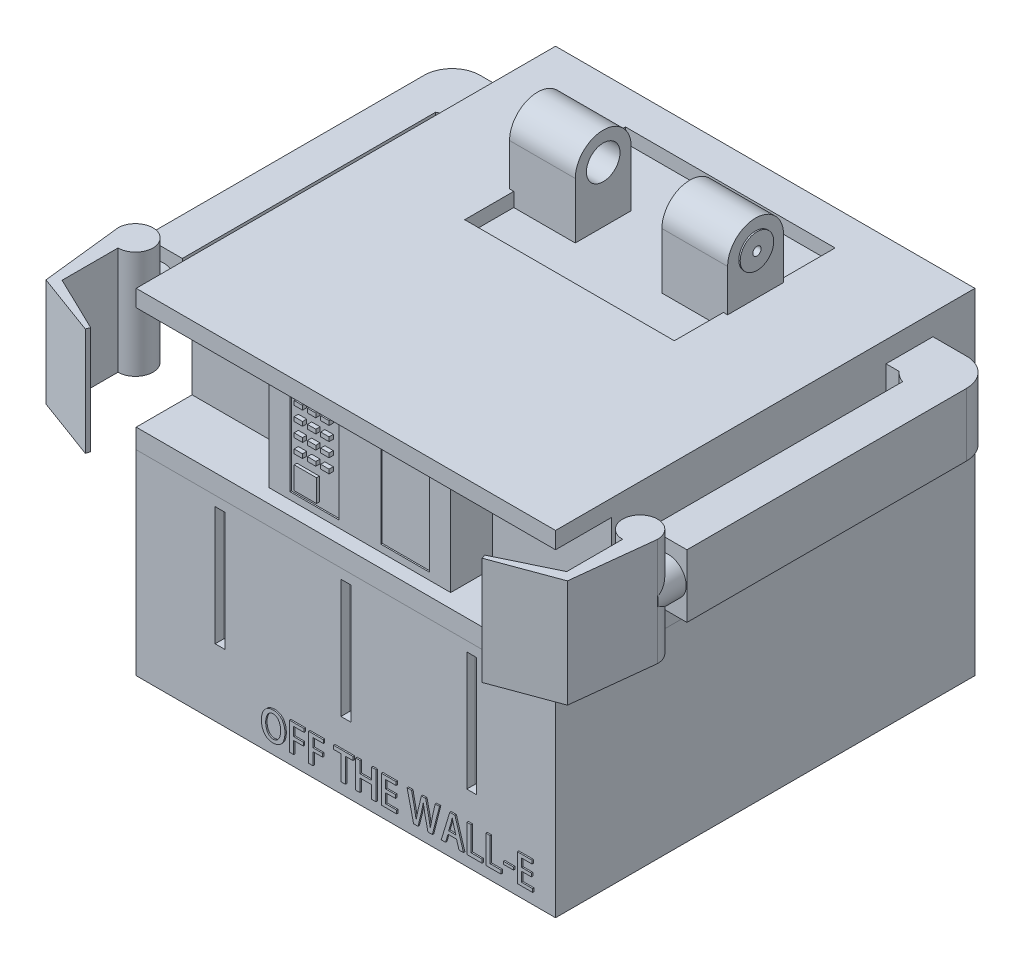
from build123d import *

# Parameters (mm, degrees)
BASE_W                                = 15
BASE_H                                = 15
BOTTOM_BASE_DEPTH                     = 7
BASE2_W                               = 15
BASE2_H                               = 15
TOP_BASE_DEPTH                        = 5
SKETCH3_W                             = 15
SKETCH3_H                             = 3.7
TOP_CUT_DEPTH                         = 2
SKETCH4_W                             = 6.5
SKETCH4_H                             = 3.7
BIG_BUTTON_PLATE_DEPTH                = 1.5
SKETCH6_W                             = 0.3
SKETCH6_H                             = 0.15
F_3X4_BUTTONS_DEPTH                   = 0.1
SKETCH9_W                             = 0.8
SKETCH9_H                             = 0.8
BIG_SQUARE_BUTTON_DEPTH               = 0.1
SKETCH6_6_W                           = 1.75
SKETCH6_6_H                           = 3.2
SKETCH6_6_W_2                         = 0.3
SKETCH6_6_H_2                         = 0.15
PHONE_DEPTH                           = 0.05
SKETCH14_W                            = 0.35
SKETCH14_H                            = 4.25
F_3_BOTTOM_SLOTS_DEPTH                = 0.35
FILLET1_R                             = 0.05
SKETCH15_W                            = 7.5
SKETCH15_H                            = 5.75
TOP_EXTRUDE_CUT_DEPTH                 = 0.5
RIGHT_HEAD_HOLDER_1_DEPTH             = 2.2
RIGHT_HEAD_HOLDER_1_DEPTH_BACK        = 0.15
SKETCH19_R                            = 0.6
RIGHT_HEAD_HOLDER_2_DEPTH             = 0.35
RIGHT_HEAD_HOLDER_2_DEPTH_BACK        = 0.2
SKETCH19_3_R                          = 0.6
SKETCH19_3_R_2                        = 0.15
LEFT_HEAD_HOLDER_1_DEPTH              = 2.2
LEFT_HEAD_HOLDER_1_DEPTH_BACK         = 0.15
SKETCH18_R                            = 0.6
LEFT_HEAD_HOLDER_2_DEPTH              = 0.35
LEFT_HEAD_HOLDER_2_DEPTH_BACK         = 0.2
SKETCH18_3_R                          = 0.6
SKETCH18_3_R_2                        = 0.15
ARMS_DEPTH                            = 2.25
CLAWS_DEPTH                           = 0.8
CLAWS_DEPTH_BACK                      = 3.05
CLAWS_2_DEPTH                         = 0.8
CLAWS_2_DEPTH_BACK                    = 3.05
SKETCH26_R                            = 0.65
CIRCLE_TO_ATTACH_ARMS_AND_CLAWS_DEPTH = 1
SKETCH28_W                            = 0.359189424
SKETCH28_H                            = 0.095238297
BOSS_EXTRUDE26_DEPTH                  = 0.05
SKETCH33_W                            = 1.285714286
SKETCH33_H                            = 1.285714286
CUT_EXTRUDE1_DEPTH                    = 2.892857143
SCALE1_SCALE                          = 1.4


with BuildPart() as part:
    # Base → Bottom base (new body)
    with BuildSketch(Plane(origin=(0, 0, 0), x_dir=(1, 0, 0), z_dir=(0, 1, 0))):
        Rectangle(BASE_W, BASE_H)
    extrude(amount=BOTTOM_BASE_DEPTH)

    # Sketch14 → 3 bottom slots (cut)
    with BuildSketch(Plane.XY.offset(7.5)):
        with Locations((0, 4.525)):
            Rectangle(SKETCH14_W, SKETCH14_H)
        with Locations((4.5, 4.525)):
            Rectangle(SKETCH14_W, SKETCH14_H)
        with Locations((-4.5, 4.525)):
            Rectangle(SKETCH14_W, SKETCH14_H)
    extrude(amount=-F_3_BOTTOM_SLOTS_DEPTH, mode=Mode.SUBTRACT)

    # Fillet1
    fillet1_edges = [part.edges().sort_by_distance(p)[0] for p in [
        (-0.175, 4.525, 7.15),
        (-4.675, 4.525, 7.15),
        (4.675, 4.525, 7.15),
        (4.5, 6.65, 7.15),
        (0.175, 4.525, 7.15),
        (0, 6.65, 7.15),
        (4.325, 4.525, 7.15),
        (4.5, 2.4, 7.15),
        (0, 2.4, 7.15),
        (-4.5, 2.4, 7.15),
        (-4.5, 6.65, 7.15),
        (-4.325, 4.525, 7.15),
    ]]
    fillet(fillet1_edges, radius=FILLET1_R)

    # Sketch28 → Boss-Extrude26 (add)
    # profile 1 of 12: a face of its own
    with BuildSketch(Plane.XY.offset(7.5)):
        with BuildLine():
            add(Edge.make_bspline(
                [(-2.542773415, 1.438775136), (-2.55882584, 1.438110923), (-2.59017136, 1.436813916), (-2.635834672, 1.429654226), (-2.678976734, 1.41865114), (-2.719463386, 1.403035452), (-2.757423202, 1.38326681), (-2.792716073, 1.359116703), (-2.825399223, 1.330752787), (-2.855279169, 1.298345473), (-2.882055278, 1.262197262), (-2.905669966, 1.222690536), (-2.925377124, 1.17977718), (-2.941932195, 1.133846801), (-2.954655386, 1.08466898), (-2.964079137, 1.032377645), (-2.969951963, 0.976854424), (-2.97105014, 0.938758011), (-2.971613422, 0.919217401)],
                knots=[0, 0, 0, 0, 1.01693825, 1.985772131, 2.921518734, 3.832117633, 4.727948323, 5.626511184, 6.534414133, 7.463288783, 8.412839634, 9.378967074, 10.373196777, 11.399194858, 12.46754142, 13.586614818, 14.762113956, 16, 16, 16, 16], degree=3))
            add(Edge.make_bspline(
                [(-2.971613422, 0.919217401), (-2.971208289, 0.900429172), (-2.970416523, 0.863710668), (-2.964426968, 0.810220053), (-2.956119813, 0.759588063), (-2.943575482, 0.712087769), (-2.928381776, 0.667333139), (-2.909052276, 0.625858504), (-2.886964026, 0.587076746), (-2.8612577, 0.55170149), (-2.832800775, 0.519545639), (-2.801228268, 0.491619405), (-2.766992422, 0.46781399), (-2.730017847, 0.448191723), (-2.690284694, 0.432873966), (-2.647883002, 0.421784598), (-2.602861971, 0.414647273), (-2.571917352, 0.413420404), (-2.556080466, 0.412792516)],
                knots=[0, 0, 0, 0, 1.222557966, 2.38928844, 3.500048728, 4.559063003, 5.583344684, 6.572073494, 7.532658458, 8.483942143, 9.413076429, 10.322121769, 11.220566177, 12.121066096, 13.040014193, 13.985715855, 14.969126498, 16, 16, 16, 16], degree=3))
            add(Edge.make_bspline(
                [(-2.556080466, 0.412792516), (-2.54075349, 0.413188806), (-2.510669922, 0.41396664), (-2.466682885, 0.420165519), (-2.424842983, 0.430077083), (-2.38526705, 0.444305975), (-2.348009795, 0.462822842), (-2.312864376, 0.485189664), (-2.279982063, 0.511738917), (-2.249253561, 0.542102642), (-2.221648907, 0.576876857), (-2.197202941, 0.615672953), (-2.176945288, 0.65894639), (-2.159942527, 0.706133976), (-2.146555767, 0.757497133), (-2.136920145, 0.812927523), (-2.130587189, 0.872528944), (-2.12942961, 0.913657954), (-2.12883171, 0.934901455)],
                knots=[0, 0, 0, 0, 0.964759122, 1.89361537, 2.791129421, 3.668077106, 4.535429534, 5.405715028, 6.285894481, 7.191747456, 8.120239528, 9.075412678, 10.072429751, 11.12252868, 12.229792465, 13.410030886, 14.662257747, 16, 16, 16, 16], degree=3))
            add(Edge.make_bspline(
                [(-2.12883171, 0.934901455), (-2.129145052, 0.95299104), (-2.12975776, 0.988363246), (-2.134927432, 1.040094869), (-2.143460291, 1.089133126), (-2.154882139, 1.135699503), (-2.169797366, 1.179671389), (-2.188169567, 1.221026594), (-2.209857994, 1.259758826), (-2.234383469, 1.295895008), (-2.262423291, 1.328524563), (-2.293489849, 1.357214635), (-2.327622631, 1.381751634), (-2.365000455, 1.401492806), (-2.405152647, 1.417631026), (-2.44846881, 1.428920554), (-2.494667177, 1.436482788), (-2.526508763, 1.437935279), (-2.542773415, 1.438775136)],
                knots=[0, 0, 0, 0, 1.181997023, 2.311265979, 3.393394717, 4.432710499, 5.441572568, 6.423779709, 7.385757606, 8.339154063, 9.273212536, 10.190881701, 11.096730823, 12.012033381, 12.946898792, 13.918455472, 14.931549697, 16, 16, 16, 16], degree=3))
        make_face()
        with BuildLine():
            add(Edge.make_bspline(
                [(-2.548066636, 1.31991609), (-2.537165417, 1.318983992), (-2.515855441, 1.317161903), (-2.484981242, 1.31054518), (-2.456310213, 1.300351113), (-2.429814447, 1.286594966), (-2.405742403, 1.269172675), (-2.383543332, 1.248629521), (-2.363840451, 1.224383101), (-2.346717009, 1.196948695), (-2.331589955, 1.167451879), (-2.318430785, 1.13658356), (-2.306908464, 1.104796692), (-2.29799648, 1.071757069), (-2.290669647, 1.037788882), (-2.285934581, 1.002655396), (-2.282735348, 0.966518333), (-2.282427136, 0.942026369), (-2.282270891, 0.929610449)],
                knots=[0, 0, 0, 0, 0.999589655, 1.954022852, 2.877517249, 3.773878129, 4.673599429, 5.586311784, 6.531597741, 7.520501744, 8.537853166, 9.559417173, 10.586727125, 11.626167667, 12.685579831, 13.761408337, 14.865171654, 16, 16, 16, 16], degree=3))
            add(Edge.make_bspline(
                [(-2.282270891, 0.929610449), (-2.282515675, 0.916063238), (-2.282995612, 0.889501882), (-2.28596674, 0.850426095), (-2.29128527, 0.813015414), (-2.298562117, 0.777117744), (-2.308300047, 0.742958305), (-2.31968806, 0.710261892), (-2.333651813, 0.679388185), (-2.349250923, 0.650198013), (-2.36712996, 0.623475447), (-2.387135503, 0.599901927), (-2.409359173, 0.579747293), (-2.433601588, 0.563029952), (-2.460016367, 0.549834402), (-2.488459567, 0.540284041), (-2.518878394, 0.533600178), (-2.539982794, 0.532311215), (-2.550789459, 0.531651192)],
                knots=[0, 0, 0, 0, 1.215141369, 2.382468418, 3.512223075, 4.602497428, 5.664896563, 6.695933009, 7.704955915, 8.700973005, 9.661508233, 10.583141316, 11.467103885, 12.344670232, 13.216342825, 14.106081872, 15.030205112, 16, 16, 16, 16], degree=3))
            add(Edge.make_bspline(
                [(-2.550789459, 0.531651192), (-2.561404923, 0.532397393), (-2.582186513, 0.53385821), (-2.612268391, 0.540448671), (-2.640452786, 0.550215414), (-2.666522509, 0.563599601), (-2.690700767, 0.580196186), (-2.712602066, 0.600478458), (-2.732893267, 0.623866029), (-2.750494325, 0.650723065), (-2.766275355, 0.679738522), (-2.7800325, 0.710402286), (-2.791879883, 0.742433556), (-2.80114964, 0.77598823), (-2.808854497, 0.810774186), (-2.814005122, 0.846973579), (-2.817330483, 0.884511626), (-2.817764383, 0.910013807), (-2.817985276, 0.922996691)],
                knots=[0, 0, 0, 0, 0.968573833, 1.896149455, 2.796477749, 3.679461465, 4.558257033, 5.460120664, 6.392036362, 7.372592241, 8.379386201, 9.399199485, 10.432362265, 11.48798156, 12.568687675, 13.676620176, 14.817192429, 16, 16, 16, 16], degree=3))
            add(Edge.make_bspline(
                [(-2.817985276, 0.922996691), (-2.817906472, 0.93566455), (-2.817750586, 0.960723784), (-2.814512109, 0.997678677), (-2.809767876, 1.033623912), (-2.802495327, 1.068302048), (-2.793463414, 1.101907221), (-2.782305831, 1.13439706), (-2.768830302, 1.165645515), (-2.753760089, 1.19566964), (-2.736462485, 1.223413999), (-2.716446665, 1.247918927), (-2.69405673, 1.268812858), (-2.669357094, 1.286293929), (-2.642284347, 1.300124753), (-2.612952929, 1.310551542), (-2.58132124, 1.317484158), (-2.559390721, 1.319029602), (-2.548066636, 1.31991609)],
                knots=[0, 0, 0, 0, 1.136547726, 2.248289582, 3.326834991, 4.389002452, 5.425786828, 6.448433384, 7.469124786, 8.477926495, 9.461316408, 10.397265518, 11.309260955, 12.201738065, 13.104381261, 14.028854752, 14.989125284, 16, 16, 16, 16], degree=3))
        make_face(mode=Mode.SUBTRACT)
    # profile 2 of 12: a face of its own
    with BuildSketch(Plane.XY.offset(7.5)):
        Polygon((-1.814205801, 0.421490419), (-1.814205801, 0.860354587), (-1.471996241, 0.860354587), (-1.471996241, 0.979213633), (-1.814205801, 0.979213633), (-1.814205801, 1.295728633), (-1.445873374, 1.295728633), (-1.445873374, 1.414587678), (-1.967645167, 1.414587678), (-1.967645167, 0.421490419), align=None)
    # profile 3 of 12: a face of its own
    with BuildSketch(Plane.XY.offset(7.5)):
        Polygon((-1.12486327, 0.421490419), (-1.12486327, 0.860354587), (-0.782653711, 0.860354587), (-0.782653711, 0.979213633), (-1.12486327, 0.979213633), (-1.12486327, 1.295728633), (-0.756530843, 1.295728633), (-0.756530843, 1.414587678), (-1.278302637, 1.414587678), (-1.278302637, 0.421490419), align=None)
    # profile 4 of 12: a face of its own
    with BuildSketch(Plane.XY.offset(7.5)):
        Polygon((0.306506351, 1.425859116), (-0.386370222, 1.425859116), (-0.386370222, 1.296550924), (-0.11730469, 1.296550924), (-0.11730469, 0.426659447), (0.036134676, 0.426659447), (0.036134676, 1.296550924), (0.306506351, 1.296550924), align=None)
    # profile 5 of 12: a face of its own
    with BuildSketch(Plane.XY.offset(7.5)):
        Polygon((1.124570067, 1.428519382), (0.971130701, 1.428519382), (0.971130701, 1.015778081), (0.556165007, 1.015778081), (0.556165007, 1.428519382), (0.40272564, 1.428519382), (0.40272564, 0.429720894), (0.556165007, 0.429720894), (0.556165007, 0.884258782), (0.971130701, 0.884258782), (0.971130701, 0.429720894), (1.124570067, 0.429720894), align=None)
    # profile 6 of 12: a face of its own
    with BuildSketch(Plane.XY.offset(7.5)):
        Polygon((1.868437532, 0.543839587), (1.475288381, 0.543839587), (1.475288381, 0.884542045), (1.825334801, 0.884542045), (1.825334801, 1.00340109), (1.475288381, 1.00340109), (1.475288381, 1.295728633), (1.846233095, 1.295728633), (1.846233095, 1.414587678), (1.321849015, 1.414587678), (1.321849015, 0.424980542), (1.868437532, 0.424980542), align=None)
    # profile 7 of 12: a face of its own
    with BuildSketch(Plane.XY.offset(7.5)):
        with BuildLine():
            Line((3.245765887, 1.425831067), (3.139055562, 0.953960298))
            add(Edge.make_bspline(
                [(3.139055562, 0.953960298), (3.132663135, 0.924375836), (3.119998725, 0.865764336), (3.1020337, 0.778168135), (3.085930576, 0.690954756), (3.07705063, 0.63264649), (3.07260538, 0.603457706)],
                knots=[0, 0, 0, 0, 1.01788206, 2.01658543, 3.007114032, 4, 4, 4, 4], degree=3))
            Line((3.07260538, 0.603457706), (3.068782909, 0.603457706))
            add(Edge.make_bspline(
                [(3.068782909, 0.603457706), (3.064621305, 0.632259681), (3.056258443, 0.690138076), (3.041702599, 0.777037426), (3.025081799, 0.864413942), (3.012568145, 0.922642729), (3.006278837, 0.951908261)],
                knots=[0, 0, 0, 0, 0.986163973, 1.981724799, 2.985623747, 4, 4, 4, 4], degree=3))
            Line((3.006278837, 0.951908261), (2.902210694, 1.426964854))
            Line((2.902210694, 1.426964854), (2.751254624, 1.426964854))
            Line((2.751254624, 1.426964854), (2.638037571, 0.954592148))
            add(Edge.make_bspline(
                [(2.638037571, 0.954592148), (2.630872403, 0.923406884), (2.61681508, 0.862224604), (2.596699251, 0.772299255), (2.578665214, 0.686135246), (2.569505115, 0.629634853), (2.565046708, 0.602134954)],
                knots=[0, 0, 0, 0, 1.066520868, 2.092404214, 3.071534041, 4, 4, 4, 4], degree=3))
            Line((2.565046708, 0.602134954), (2.562559536, 0.602140121))
            add(Edge.make_bspline(
                [(2.562559536, 0.602140121), (2.560300099, 0.615428557), (2.55570602, 0.642447728), (2.54874011, 0.683653591), (2.541417455, 0.726190662), (2.530665073, 0.785077644), (2.516739752, 0.860534551), (2.504767173, 0.921245095), (2.498720165, 0.951908261)],
                knots=[0, 0, 0, 0, 0.682369738, 1.387451828, 2.115611866, 2.867419731, 4.417822979, 6, 6, 6, 6], degree=3))
            Line((2.498720165, 0.951908261), (2.399891357, 1.426964854))
            Line((2.399891357, 1.426964854), (2.239838602, 1.426964854))
            Line((2.239838602, 1.426964854), (2.472766701, 0.425831067))
            Line((2.472766701, 0.425831067), (2.631530844, 0.425831067))
            Line((2.631530844, 0.425831067), (2.749953278, 0.910045241))
            add(Edge.make_bspline(
                [(2.749953278, 0.910045241), (2.753617344, 0.924555813), (2.760831191, 0.953124366), (2.770726599, 0.995475919), (2.780283244, 1.03650652), (2.791843212, 1.089662653), (2.80499902, 1.155496718), (2.813336322, 1.208364765), (2.817503292, 1.234788132)],
                knots=[0, 0, 0, 0, 0.811805786, 1.598290927, 2.359154387, 3.097023541, 4.549096894, 6, 6, 6, 6], degree=3))
            Line((2.817503292, 1.234788132), (2.821527277, 1.234976727))
            add(Edge.make_bspline(
                [(2.821527277, 1.234976727), (2.82469568, 1.208365765), (2.831034187, 1.155129548), (2.844522693, 1.075106184), (2.860318642, 0.993345399), (2.872490004, 0.938213226), (2.878727794, 0.90995814)],
                knots=[0, 0, 0, 0, 0.973823886, 1.948170723, 2.948443182, 4, 4, 4, 4], degree=3))
            Line((2.878727794, 0.90995814), (2.986798147, 0.425831067))
            Line((2.986798147, 0.425831067), (3.144260944, 0.425831067))
            Line((3.144260944, 0.425831067), (3.399324648, 1.426964854))
            Line((3.399324648, 1.426964854), (3.245765887, 1.425831067))
        make_face()
    # profile 8 of 12: a face of its own
    with BuildSketch(Plane.XY.offset(7.5)):
        Polygon((3.9523852, 1.426512188), (3.766939047, 1.426512188), (3.461305192, 0.421347588), (3.616753782, 0.421347588), (3.702947065, 0.715229844), (4.008541429, 0.715229844), (4.098652588, 0.421347588), (4.257979564, 0.421347588), align=None)
        with BuildLine():
            Line((3.726454323, 0.83408889), (3.806117812, 1.098552471))
            add(Edge.make_bspline(
                [(3.806117812, 1.098552471), (3.810378493, 1.114590054), (3.819076241, 1.147329146), (3.83055211, 1.197153881), (3.841903727, 1.246876142), (3.849377993, 1.279761021), (3.853028805, 1.295823669)],
                knots=[0, 0, 0, 0, 0.981880665, 2.004409445, 3.025252049, 4, 4, 4, 4], degree=3))
            Line((3.853028805, 1.295823669), (3.855744247, 1.295897852))
            add(Edge.make_bspline(
                [(3.855744247, 1.295897852), (3.859406222, 1.279929837), (3.866906617, 1.247224421), (3.878892873, 1.19768297), (3.891585867, 1.147389791), (3.900662415, 1.113901091), (3.905183009, 1.097221969)],
                knots=[0, 0, 0, 0, 0.960134074, 1.966530216, 2.987225846, 4, 4, 4, 4], degree=3))
            Line((3.905183009, 1.097221969), (3.983728212, 0.83408889))
            Line((3.983728212, 0.83408889), (3.726454323, 0.83408889))
        make_face(mode=Mode.SUBTRACT)
    # profile 9 of 12: a face of its own
    with BuildSketch(Plane.XY.offset(7.5)):
        Polygon((4.92031401, 0.555082791), (4.53500172, 0.555082791), (4.53500172, 1.426280411), (4.381562353, 1.426280411), (4.381562353, 0.425831067), (4.92031401, 0.425831067), align=None)
    # profile 10 of 12: a face of its own
    with BuildSketch(Plane.XY.offset(7.5)):
        Polygon((5.597562813, 0.555082791), (5.212250522, 0.555082791), (5.212250522, 1.426280411), (5.058811156, 1.426280411), (5.058811156, 0.425831067), (5.597562813, 0.425831067), align=None)
    # profile 11 of 12: a face of its own
    with BuildSketch(Plane.XY.offset(7.5)):
        with Locations((5.867201512, 0.823034374)):
            Rectangle(SKETCH28_W, SKETCH28_H)
    # profile 12 of 12: a face of its own
    with BuildSketch(Plane.XY.offset(7.5)):
        Polygon((6.730116434, 0.543839587), (6.336967283, 0.543839587), (6.336967283, 0.884542045), (6.687013703, 0.884542045), (6.687013703, 1.00340109), (6.336967283, 1.00340109), (6.336967283, 1.295728633), (6.707911996, 1.295728633), (6.707911996, 1.414587678), (6.183527917, 1.414587678), (6.183527917, 0.424980542), (6.730116434, 0.424980542), align=None)
    extrude(amount=BOSS_EXTRUDE26_DEPTH)

    # Sketch33 → Cut-Extrude1 (cut)
    with BuildSketch(Plane.XZ):
        with Locations((-6.414285714, 0.1)):
            Rectangle(SKETCH33_W, SKETCH33_H)
        with Locations((6.414285714, 0.1)):
            Rectangle(SKETCH33_W, SKETCH33_H)
    extrude(amount=-CUT_EXTRUDE1_DEPTH, mode=Mode.SUBTRACT)


with BuildPart() as body_2:
    # Base2 → Top base (new body)
    with BuildSketch(Plane(origin=(0, 7, 0), x_dir=(1, 0, 0), z_dir=(0, 1, 0))):
        Rectangle(BASE2_W, BASE2_H)
    extrude(amount=TOP_BASE_DEPTH)

    # Sketch3 → Top cut (cut)
    with BuildSketch(Plane.XY.offset(7.5)):
        with Locations((0, 9.55)):
            Rectangle(SKETCH3_W, SKETCH3_H)
    extrude(amount=-TOP_CUT_DEPTH, mode=Mode.SUBTRACT)

    # Sketch4 → Big button plate (add)
    with BuildSketch(Plane.XY.offset(5.5)):
        with Locations((0, 9.55)):
            Rectangle(SKETCH4_W, SKETCH4_H)
    extrude(amount=BIG_BUTTON_PLATE_DEPTH)

    # Sketch6 → 3x4 buttons (add)
    with BuildSketch(Plane.XY.offset(7)):
        with Locations((-1.625, 10.874059361)):
            Rectangle(SKETCH6_W, SKETCH6_H)
        with Locations((-2.1, 10.874059361)):
            Rectangle(SKETCH6_W, SKETCH6_H)
        with Locations((-1.15, 10.874059361)):
            Rectangle(SKETCH6_W, SKETCH6_H)
        with Locations((-2.1, 10.374059361)):
            Rectangle(SKETCH6_W, SKETCH6_H)
        with Locations((-1.625, 10.374059361)):
            Rectangle(SKETCH6_W, SKETCH6_H)
        with Locations((-1.15, 10.374059361)):
            Rectangle(SKETCH6_W, SKETCH6_H)
        with Locations((-2.1, 9.874059361)):
            Rectangle(SKETCH6_W, SKETCH6_H)
        with Locations((-1.625, 9.874059361)):
            Rectangle(SKETCH6_W, SKETCH6_H)
        with Locations((-1.15, 9.874059361)):
            Rectangle(SKETCH6_W, SKETCH6_H)
        with Locations((-2.1, 9.374059361)):
            Rectangle(SKETCH6_W, SKETCH6_H)
        with Locations((-1.625, 9.374059361)):
            Rectangle(SKETCH6_W, SKETCH6_H)
        with Locations((-1.15, 9.374059361)):
            Rectangle(SKETCH6_W, SKETCH6_H)
    extrude(amount=F_3X4_BUTTONS_DEPTH)

    # Sketch9 → Big square button (add)
    with BuildSketch(Plane.XY.offset(7)):
        with Locations((-1.85, 8.55732297)):
            Rectangle(SKETCH9_W, SKETCH9_H)
    extrude(amount=BIG_SQUARE_BUTTON_DEPTH)

    # Sketch6_6 → phone (cut)
    # profile 1 of 2: a face of its own
    with BuildSketch(Plane.XY.offset(7)):
        with Locations((-1.625, 9.55)):
            Rectangle(SKETCH6_6_W, SKETCH6_6_H)
        with Locations((-1.625, 10.874059361)):
            Rectangle(SKETCH6_6_W_2, SKETCH6_6_H_2, mode=Mode.SUBTRACT)
        with Locations((-2.1, 10.874059361)):
            Rectangle(SKETCH6_6_W_2, SKETCH6_6_H_2, mode=Mode.SUBTRACT)
        with Locations((-1.15, 10.874059361)):
            Rectangle(SKETCH6_6_W_2, SKETCH6_6_H_2, mode=Mode.SUBTRACT)
        with Locations((-2.1, 10.374059361)):
            Rectangle(SKETCH6_6_W_2, SKETCH6_6_H_2, mode=Mode.SUBTRACT)
        with Locations((-1.625, 10.374059361)):
            Rectangle(SKETCH6_6_W_2, SKETCH6_6_H_2, mode=Mode.SUBTRACT)
        with Locations((-1.15, 10.374059361)):
            Rectangle(SKETCH6_6_W_2, SKETCH6_6_H_2, mode=Mode.SUBTRACT)
        with Locations((-2.1, 9.874059361)):
            Rectangle(SKETCH6_6_W_2, SKETCH6_6_H_2, mode=Mode.SUBTRACT)
        with Locations((-1.625, 9.874059361)):
            Rectangle(SKETCH6_6_W_2, SKETCH6_6_H_2, mode=Mode.SUBTRACT)
        with Locations((-1.15, 9.874059361)):
            Rectangle(SKETCH6_6_W_2, SKETCH6_6_H_2, mode=Mode.SUBTRACT)
        with Locations((-2.1, 9.374059361)):
            Rectangle(SKETCH6_6_W_2, SKETCH6_6_H_2, mode=Mode.SUBTRACT)
        with Locations((-1.625, 9.374059361)):
            Rectangle(SKETCH6_6_W_2, SKETCH6_6_H_2, mode=Mode.SUBTRACT)
        with Locations((-1.15, 9.374059361)):
            Rectangle(SKETCH6_6_W_2, SKETCH6_6_H_2, mode=Mode.SUBTRACT)
    # profile 2 of 2: a face of its own
    with BuildSketch(Plane.XY.offset(7)):
        with Locations((1.625, 9.55)):
            Rectangle(SKETCH6_6_W, SKETCH6_6_H)
    extrude(amount=-PHONE_DEPTH, mode=Mode.SUBTRACT)


with BuildPart() as phone_piece_1:
    # of the separate pieces the step leaves, piece 1, a body of its own (phone_pieces)
    add(body_2.part.solids().sort_by_distance((-7.5, 7, 7.5))[0])

    # Sketch15 → Top extrude cut (cut)
    with BuildSketch(Plane(origin=(0, 12, 0), x_dir=(1, 0, 0), z_dir=(0, 1, 0))):
        with Locations((0, 3.375)):
            Rectangle(SKETCH15_W, SKETCH15_H)
    extrude(amount=-TOP_EXTRUDE_CUT_DEPTH, mode=Mode.SUBTRACT)

    # Sketch19 → Right head holder 1 (add, two sides: drawn at the far end of the back side and taken through both)
    with BuildSketch(Plane.ZY.offset(-3.75).offset(-RIGHT_HEAD_HOLDER_1_DEPTH_BACK)):
        with BuildLine():
            ThreePointArc((-2.255590817, 13.5), (-3.255590817, 14.5), (-4.255590817, 13.5))
            Line((-4.255590817, 13.5), (-4.255590817, 11.5))
            Line((-4.255590817, 11.5), (-2.255590817, 11.5))
            Line((-2.255590817, 11.5), (-2.255590817, 13.5))
        make_face()
        with Locations((-3.255590817, 13.5)):
            Circle(SKETCH19_R, mode=Mode.SUBTRACT)
    extrude(amount=RIGHT_HEAD_HOLDER_1_DEPTH + RIGHT_HEAD_HOLDER_1_DEPTH_BACK)

    # Sketch19_3 → Right head holder 2 (add, two sides: drawn at the far end of the back side and taken through both)
    with BuildSketch(Plane.ZY.offset(-3.75).offset(-RIGHT_HEAD_HOLDER_2_DEPTH_BACK)):
        with Locations((-3.255590817, 13.5)):
            Circle(SKETCH19_3_R)
        with Locations((-3.255590817, 13.5)):
            Circle(SKETCH19_3_R_2, mode=Mode.SUBTRACT)
    extrude(amount=RIGHT_HEAD_HOLDER_2_DEPTH + RIGHT_HEAD_HOLDER_2_DEPTH_BACK)

    # Sketch18 → Left head holder 1 (add, two sides: drawn at the far end of the back side and taken through both)
    with BuildSketch(Plane(origin=(-3.75, 0, 0), x_dir=(0, 0, -1), z_dir=(1, 0, 0)).offset(-LEFT_HEAD_HOLDER_1_DEPTH_BACK)):
        with BuildLine():
            Line((2.255590817, 11.5), (4.255590817, 11.5))
            Line((4.255590817, 11.5), (4.255590817, 13.5))
            ThreePointArc((4.255590817, 13.5), (3.255590817, 14.5), (2.255590817, 13.5))
            Line((2.255590817, 13.5), (2.255590817, 11.5))
        make_face()
        with Locations((3.255590817, 13.5)):
            Circle(SKETCH18_R, mode=Mode.SUBTRACT)
    extrude(amount=LEFT_HEAD_HOLDER_1_DEPTH + LEFT_HEAD_HOLDER_1_DEPTH_BACK)

    # Sketch18_3 → Left head holder 2 (add, two sides: drawn at the far end of the back side and taken through both)
    with BuildSketch(Plane(origin=(-3.75, 0, 0), x_dir=(0, 0, -1), z_dir=(1, 0, 0)).offset(-LEFT_HEAD_HOLDER_2_DEPTH_BACK)):
        with Locations((3.255590817, 13.5)):
            Circle(SKETCH18_3_R)
        with Locations((3.255590817, 13.5)):
            Circle(SKETCH18_3_R_2, mode=Mode.SUBTRACT)
    extrude(amount=LEFT_HEAD_HOLDER_2_DEPTH + LEFT_HEAD_HOLDER_2_DEPTH_BACK)

    # Sketch21 → arms (add)
    with BuildSketch(Plane(origin=(0, 9, 0), x_dir=(1, 0, 0), z_dir=(0, 1, 0))):
        with BuildLine():
            Line((7.5, 4.322915521), (7.964094701, 4.322915521))
            ThreePointArc((7.964094701, 4.322915521), (8.141740127, 4.170333854), (8.35, 4.0632503))
            Line((8.35, 4.0632503), (8.35, -5))
            Line((8.35, -5), (9.7, -5))
            Line((9.7, -5), (9.7, 5))
            ThreePointArc((9.7, 5), (9.407106781, 5.707106781), (8.7, 6))
            Line((8.7, 6), (7.5, 6))
            Line((7.5, 6), (7.5, 4.322915521))
        make_face()
        with BuildLine():
            Line((-7.5, 6), (-8.7, 6))
            ThreePointArc((-8.7, 6), (-9.407106781, 5.707106781), (-9.7, 5))
            Line((-9.7, 5), (-9.7, -5))
            Line((-9.7, -5), (-8.35, -5))
            Line((-8.35, -5), (-8.35, 4.0632503))
            ThreePointArc((-8.35, 4.0632503), (-8.141740127, 4.170333854), (-7.964094701, 4.322915521))
            Line((-7.964094701, 4.322915521), (-7.5, 4.322915521))
            Line((-7.5, 4.322915521), (-7.5, 6))
        make_face()
    extrude(amount=ARMS_DEPTH)



with BuildPart() as phone_piece_2:
    # of the separate pieces the step leaves, piece 2, a body of its own (phone_pieces)
    add(body_2.part.solids().sort_by_distance((-2.25, 8.95732297, 7))[0])


with BuildPart() as body_4:
    # Sketch25 → claws (new, two sides: drawn at the far end of the back side and taken through both)
    with BuildSketch(Plane(origin=(0, 11.25, 0), x_dir=(1, 0, 0), z_dir=(0, 1, 0)).offset(-CLAWS_DEPTH_BACK)):
        with BuildLine():
            ThreePointArc((9.65, -6), (8.583058262, -5.558058262), (9.025, -6.625))
            Line((9.025, -6.625), (9.025, -8.625))
            Line((9.025, -8.625), (7.048208811, -9.580762133))
            Line((7.048208811, -9.580762133), (7.100145112, -9.721483918))
            Line((7.100145112, -9.721483918), (9.325961764, -8.9))
            Line((9.325961764, -8.9), (9.65, -6))
        make_face()
    extrude(amount=CLAWS_DEPTH + CLAWS_DEPTH_BACK)


with BuildPart() as body_5:
    # Sketch25 → claws 2 (new, two sides: drawn at the far end of the back side and taken through both)
    with BuildSketch(Plane(origin=(0, 11.25, 0), x_dir=(1, 0, 0), z_dir=(0, 1, 0)).offset(-CLAWS_2_DEPTH_BACK)):
        with BuildLine():
            Line((-9.325961764, -8.9), (-7.100145112, -9.721483918))
            Line((-7.100145112, -9.721483918), (-7.048208811, -9.580762133))
            Line((-7.048208811, -9.580762133), (-9.025, -8.625))
            Line((-9.025, -8.625), (-9.025, -6.625))
            ThreePointArc((-9.025, -6.625), (-8.583058262, -5.558058262), (-9.65, -6))
            Line((-9.65, -6), (-9.325961764, -8.9))
        make_face()
    extrude(amount=CLAWS_2_DEPTH + CLAWS_2_DEPTH_BACK)


with BuildPart() as phone_piece_1_1:
    add(phone_piece_1.part)

    add(body_4.part)  # circle to attach arms and claws merges body 4

    add(body_5.part)  # circle to attach arms and claws merges body 5
    # Sketch26 → circle to attach arms and claws (add)
    with BuildSketch(Plane.XY.offset(5)):
        with Locations((9.025, 10.125)):
            Circle(SKETCH26_R)
        with Locations((-9.025, 10.125)):
            Circle(SKETCH26_R)
    extrude(amount=CIRCLE_TO_ATTACH_ARMS_AND_CLAWS_DEPTH)


with BuildPart() as phone_piece_2_1:
    # Scale1: scaled about (0, 0, 0)
    add(phone_piece_2.part.scale(SCALE1_SCALE))


with BuildPart() as phone_piece_1_2:
    # Scale1: scaled about (0, 0, 0)
    add(phone_piece_1_1.part.scale(SCALE1_SCALE))


with BuildPart() as part_1:
    # Scale1: scaled about (0, 0, 0)
    add(part.part.scale(SCALE1_SCALE))


solid = Compound([phone_piece_2_1.part, phone_piece_1_2.part, part_1.part])
